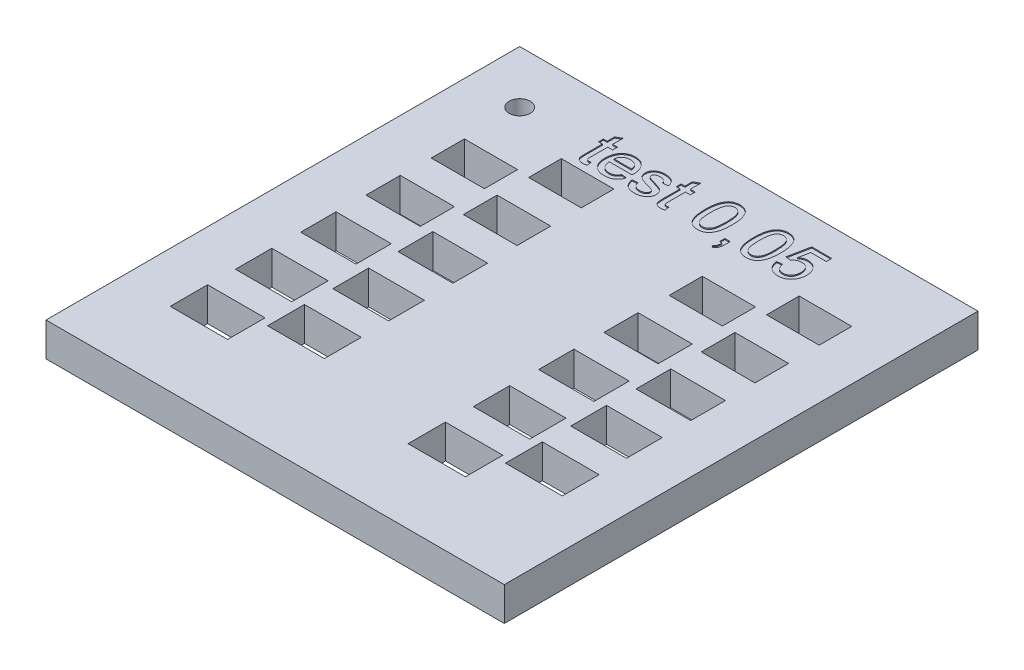
from build123d import *

# Parameters (mm, degrees)
SKETCH_1_W          = 43.5396
SKETCH_1_H          = 45
SKETCH_1_R          = 1
SKETCH_1_W_2        = 5.3
SKETCH_1_H_2        = 3.4
SKETCH_1_W_3        = 5.35
SKETCH_1_H_3        = 3.45
SKETCH_1_W_4        = 5.4
SKETCH_1_H_4        = 3.5
SKETCH_1_W_5        = 5.45
SKETCH_1_H_5        = 3.55
SKETCH_1_W_6        = 5.1
SKETCH_1_H_6        = 3.2
SKETCH_1_W_7        = 5.15
SKETCH_1_H_7        = 3.25
SKETCH_1_W_8        = 5.25
SKETCH_1_H_8        = 3.35
SKETCH_1_W_9        = 5.2
SKETCH_1_H_9        = 3.3
SKETCH_1_W_10       = 5.05
SKETCH_1_H_10       = 3.15
SKETCH_1_W_11       = 5
SKETCH_1_H_11       = 3.1
EXTRUDE_1_DEPTH     = 3.2
CUT_EXTRUDE_1_DEPTH = 0.1


with BuildPart() as part:
    # Эскиз1 → Бобышка-Вытянуть1 (new body)
    with BuildSketch(Plane(origin=(0, 0, 0), x_dir=(1, 0, 0), z_dir=(0, 1, 0))):
        with Locations((21.858709774, 22.465883459)):
            Rectangle(SKETCH_1_W, SKETCH_1_H)
        with Locations((5.088909774, 39.965883459)):
            Circle(SKETCH_1_R, mode=Mode.SUBTRACT)
        with Locations((13.788909774, 17.865583459)):
            Rectangle(SKETCH_1_W_2, SKETCH_1_H_2, mode=Mode.SUBTRACT)
        with Locations((36.388909774, 17.865583459)):
            Rectangle(SKETCH_1_W_2, SKETCH_1_H_2, mode=Mode.SUBTRACT)
        with Locations((30.188909774, 14.865583459)):
            Rectangle(SKETCH_1_W_3, SKETCH_1_H_3, mode=Mode.SUBTRACT)
        with Locations((36.388909774, 11.765583459)):
            Rectangle(SKETCH_1_W_4, SKETCH_1_H_4, mode=Mode.SUBTRACT)
        with Locations((30.188909774, 8.765583459)):
            Rectangle(SKETCH_1_W_5, SKETCH_1_H_5, mode=Mode.SUBTRACT)
        with Locations((7.588909774, 14.865583459)):
            Rectangle(SKETCH_1_W_3, SKETCH_1_H_3, mode=Mode.SUBTRACT)
        with Locations((13.788909774, 30.065583459)):
            Rectangle(SKETCH_1_W_6, SKETCH_1_H_6, mode=Mode.SUBTRACT)
        with Locations((36.388909774, 30.065583459)):
            Rectangle(SKETCH_1_W_6, SKETCH_1_H_6, mode=Mode.SUBTRACT)
        with Locations((7.588909774, 27.065583459)):
            Rectangle(SKETCH_1_W_7, SKETCH_1_H_7, mode=Mode.SUBTRACT)
        with Locations((30.188909774, 27.065583459)):
            Rectangle(SKETCH_1_W_7, SKETCH_1_H_7, mode=Mode.SUBTRACT)
        with Locations((7.588909774, 20.965583459)):
            Rectangle(SKETCH_1_W_8, SKETCH_1_H_8, mode=Mode.SUBTRACT)
        with Locations((30.188909774, 20.965583459)):
            Rectangle(SKETCH_1_W_8, SKETCH_1_H_8, mode=Mode.SUBTRACT)
        with Locations((13.788909774, 23.965583459)):
            Rectangle(SKETCH_1_W_9, SKETCH_1_H_9, mode=Mode.SUBTRACT)
        with Locations((36.388909774, 23.965583459)):
            Rectangle(SKETCH_1_W_9, SKETCH_1_H_9, mode=Mode.SUBTRACT)
        with Locations((7.588909774, 33.165583459)):
            Rectangle(SKETCH_1_W_10, SKETCH_1_H_10, mode=Mode.SUBTRACT)
        with Locations((30.188909774, 33.165583459)):
            Rectangle(SKETCH_1_W_10, SKETCH_1_H_10, mode=Mode.SUBTRACT)
        with Locations((36.388909774, 36.165583459)):
            Rectangle(SKETCH_1_W_11, SKETCH_1_H_11, mode=Mode.SUBTRACT)
        with Locations((13.788909774, 36.165583459)):
            Rectangle(SKETCH_1_W_11, SKETCH_1_H_11, mode=Mode.SUBTRACT)
        with Locations((13.788909774, 11.765583459)):
            Rectangle(SKETCH_1_W_4, SKETCH_1_H_4, mode=Mode.SUBTRACT)
        with Locations((7.588909774, 8.765583459)):
            Rectangle(SKETCH_1_W_5, SKETCH_1_H_5, mode=Mode.SUBTRACT)
    extrude(amount=EXTRUDE_1_DEPTH)

    # Эскиз2 → Вырез-Вытянуть1 (cut)
    with BuildSketch(Plane(origin=(0, 3.2, 0), x_dir=(1, 0, 0), z_dir=(0, 1, 0))):
        with BuildLine():
            Line((13.011600713, 38.82988051), (13.062882764, 38.399592048))
            add(Edge.make_bspline(
                [(13.062882764, 38.399592048), (13.030092724, 38.392817917), (12.966626925, 38.379706446), (12.87347619, 38.366609607), (12.785855685, 38.35660389), (12.729041699, 38.355874879), (12.701504559, 38.355521535)],
                knots=[0, 0, 0, 0, 0.000100416, 0.000194358, 0.000282141, 0.000364708, 0.000364708, 0.000364708, 0.000364708], degree=3))
            add(Edge.make_bspline(
                [(12.701504559, 38.355521535), (12.660597019, 38.356637564), (12.583276952, 38.358746989), (12.474129645, 38.373211148), (12.379453273, 38.399462753), (12.298461322, 38.435567552), (12.231211238, 38.481222634), (12.174630169, 38.53332819), (12.12882532, 38.59198984), (12.098473494, 38.647203628), (12.080606149, 38.698668482), (12.068798566, 38.746659277), (12.059775998, 38.804368147), (12.050764761, 38.870823645), (12.044453563, 38.947040001), (12.041162152, 39.032322522), (12.037316483, 39.127124607), (12.03726744, 39.193390524), (12.037241738, 39.228117689)],
                knots=[0, 0, 0, 0, 0.000122724, 0.000231964, 0.000329371, 0.000416509, 0.000496737, 0.000572147, 0.00064636, 0.000719135, 0.000759938, 0.000809494, 0.000867192, 0.000935075, 0.001010667, 0.001096498, 0.001191104, 0.001295273, 0.001295273, 0.001295273, 0.001295273], degree=3))
            Line((12.037241738, 39.228117689), (12.037241738, 40.868342048))
            Line((12.037241738, 40.868342048), (11.678267379, 40.868342048))
            Line((11.678267379, 40.868342048), (11.678267379, 41.32988051))
            Line((11.678267379, 41.32988051), (12.037241738, 41.32988051))
            Line((12.037241738, 41.32988051), (12.037241738, 42.041418971))
            Line((12.037241738, 42.041418971), (12.550062251, 42.333085638))
            Line((12.550062251, 42.333085638), (12.550062251, 41.32988051))
            Line((12.550062251, 41.32988051), (13.011600713, 41.32988051))
            Line((13.011600713, 41.32988051), (13.011600713, 40.868342048))
            Line((13.011600713, 40.868342048), (12.550062251, 40.868342048))
            Line((12.550062251, 40.868342048), (12.550062251, 39.209688202))
            add(Edge.make_bspline(
                [(12.550062251, 39.209688202), (12.550258863, 39.178427593), (12.550613737, 39.122004189), (12.555506069, 39.046600478), (12.561549378, 38.989339806), (12.574270072, 38.937493723), (12.604007101, 38.890472374), (12.643680727, 38.854791057), (12.683971609, 38.834590474), (12.721328693, 38.82486318), (12.7640469, 38.818381793), (12.794424835, 38.817517014), (12.810478918, 38.817059997)],
                knots=[0, 0, 0, 0, 9.3764e-05, 0.000169237, 0.000226584, 0.000266431, 0.00032827, 0.000390156, 0.000424198, 0.000462501, 0.00050545, 0.000553587, 0.000553587, 0.000553587, 0.000553587], degree=3))
            add(Edge.make_bspline(
                [(12.810478918, 38.817059997), (12.82410351, 38.817237619), (12.853507215, 38.81762095), (12.900793275, 38.820251381), (12.954227146, 38.824200917), (12.991843213, 38.827924652), (13.011600713, 38.82988051)],
                knots=[0, 0, 0, 0, 4.0873e-05, 8.821e-05, 0.000142045, 0.000201605, 0.000201605, 0.000201605, 0.000201605], degree=3))
        make_face()
        with BuildLine():
            Line((15.4675302, 39.278598458), (15.969934046, 39.227316407))
            add(Edge.make_bspline(
                [(15.969934046, 39.227316407), (15.959632776, 39.193427985), (15.939368163, 39.126762829), (15.898251156, 39.032211477), (15.853069118, 38.942383207), (15.79968746, 38.859235476), (15.74111481, 38.78099865), (15.676190637, 38.708296776), (15.603495781, 38.642964233), (15.525732329, 38.582272674), (15.441606387, 38.52893502), (15.352004758, 38.481844229), (15.256599354, 38.442980268), (15.155662463, 38.410604414), (15.048963362, 38.385911501), (14.936700008, 38.368852509), (14.819020517, 38.356766865), (14.738663154, 38.355943384), (14.697498148, 38.355521535)],
                knots=[0, 0, 0, 0, 0.000106172, 0.000208861, 0.000308845, 0.000407543, 0.000504819, 0.00060184, 0.000699399, 0.000797647, 0.000897451, 0.000997803, 0.001100923, 0.001206086, 0.001315513, 0.00142907, 0.001546593, 0.001670032, 0.001670032, 0.001670032, 0.001670032], degree=3))
            add(Edge.make_bspline(
                [(14.697498148, 38.355521535), (14.645889414, 38.356734317), (14.545268386, 38.359098866), (14.398323629, 38.37806788), (14.259522208, 38.408074749), (14.128561841, 38.450589211), (14.006281776, 38.505993341), (13.892371491, 38.574134478), (13.786122453, 38.653438332), (13.68906411, 38.745301507), (13.601249599, 38.847684405), (13.526252418, 38.961525217), (13.461208644, 39.084095671), (13.409476946, 39.217386788), (13.368587894, 39.360064009), (13.340217363, 39.512734533), (13.322065902, 39.674792643), (13.320233299, 39.786293184), (13.31929302, 39.843502305)],
                knots=[0, 0, 0, 0, 0.00015478, 0.000301773, 0.0004437, 0.000580278, 0.000714035, 0.000845545, 0.000977756, 0.001110965, 0.001245678, 0.001381464, 0.001519098, 0.001661198, 0.001809565, 0.00196373, 0.002126547, 0.002298113, 0.002298113, 0.002298113, 0.002298113], degree=3))
            add(Edge.make_bspline(
                [(13.31929302, 39.843502305), (13.320242411, 39.902842451), (13.32208584, 40.018062927), (13.340004575, 40.185823721), (13.369638462, 40.343334753), (13.409850791, 40.491167484), (13.463134787, 40.628607769), (13.528150923, 40.755605503), (13.604497186, 40.872848288), (13.692911054, 40.978619313), (13.790741599, 41.072675556), (13.894880506, 41.156312294), (14.007513363, 41.225334917), (14.126337881, 41.282642256), (14.252499297, 41.326671511), (14.385220442, 41.359096892), (14.525511887, 41.377393645), (14.621324843, 41.379888493), (14.670254559, 41.381162561)],
                knots=[0, 0, 0, 0, 0.000177973, 0.000345569, 0.000505394, 0.000658389, 0.000804513, 0.000946783, 0.001085684, 0.001223365, 0.001359366, 0.001492265, 0.001623237, 0.001754767, 0.001887309, 0.00202335, 0.002163986, 0.00231076, 0.00231076, 0.00231076, 0.00231076], degree=3))
            add(Edge.make_bspline(
                [(14.670254559, 41.381162561), (14.717595918, 41.379945171), (14.810244339, 41.377562702), (14.945977405, 41.358440773), (15.075314606, 41.328559534), (15.197984398, 41.285158668), (15.313369394, 41.2281878), (15.422715757, 41.160191757), (15.525259633, 41.079202613), (15.62034336, 40.986323908), (15.706978788, 40.882598454), (15.781919734, 40.767623983), (15.845376072, 40.643017215), (15.89681693, 40.507825514), (15.936414214, 40.362828103), (15.965101393, 40.207930052), (15.983192886, 40.043184027), (15.985020285, 39.929822413), (15.985959687, 39.871547176)],
                knots=[0, 0, 0, 0, 0.000141972, 0.000277843, 0.000410394, 0.000539646, 0.000667221, 0.000795729, 0.000925252, 0.001058412, 0.001193836, 0.001329849, 0.001469249, 0.001612553, 0.001763017, 0.001919544, 0.00208475, 0.00225952, 0.00225952, 0.00225952, 0.00225952], degree=3))
            add(Edge.make_bspline(
                [(15.985959687, 39.871547176), (15.985715655, 39.853384373), (15.98512707, 39.809577175), (15.984136003, 39.765777129), (15.983555841, 39.74013692)],
                knots=[0, 0, 0, 0, 5.4493e-05, 0.000131433, 0.000131433, 0.000131433, 0.000131433], degree=3))
            Line((15.983555841, 39.74013692), (13.832113533, 39.74013692))
            add(Edge.make_bspline(
                [(13.832113533, 39.74013692), (13.835082372, 39.704021136), (13.840890609, 39.633364226), (13.857828275, 39.531066054), (13.880686064, 39.434926746), (13.911455343, 39.345792819), (13.947804107, 39.262665998), (13.992725061, 39.186913593), (14.042770824, 39.116853131), (14.100272159, 39.054192728), (14.162327253, 38.998456815), (14.228733647, 38.949563862), (14.299373576, 38.909011025), (14.37322512, 38.87491914), (14.450978404, 38.849264953), (14.532278591, 38.830906059), (14.617579422, 38.819420163), (14.675827152, 38.817856739), (14.705510969, 38.817059997)],
                knots=[0, 0, 0, 0, 0.000108673, 0.000212609, 0.000310752, 0.000404762, 0.000495151, 0.000582417, 0.000668486, 0.000753002, 0.00083698, 0.000918396, 0.000999894, 0.001080931, 0.001162015, 0.001245016, 0.00133069, 0.001419722, 0.001419722, 0.001419722, 0.001419722], degree=3))
            add(Edge.make_bspline(
                [(14.705510969, 38.817059997), (14.748851448, 38.818511107), (14.832812907, 38.821322273), (14.953961685, 38.841044629), (15.065013585, 38.8758191), (15.166749028, 38.92409062), (15.258999191, 38.988078436), (15.339495202, 39.069981659), (15.411062122, 39.167051679), (15.448285074, 39.240581727), (15.4675302, 39.278598458)],
                knots=[0, 0, 0, 0, 0.000130008, 0.000251858, 0.000366914, 0.000478015, 0.000588493, 0.000701812, 0.000821049, 0.000948692, 0.000948692, 0.000948692, 0.000948692], degree=3))
        make_face()
        with BuildLine():
            Line((13.832113533, 40.201675381), (15.473139174, 40.201675381))
            add(Edge.make_bspline(
                [(15.473139174, 40.201675381), (15.469911102, 40.227083879), (15.463599514, 40.276763051), (15.450314636, 40.348617764), (15.432596834, 40.415564246), (15.411258457, 40.477351044), (15.385237754, 40.534096442), (15.355838598, 40.585887511), (15.322988733, 40.633277346), (15.297457775, 40.660818349), (15.284837892, 40.674431792)],
                knots=[0, 0, 0, 0, 7.6831e-05, 0.000150222, 0.000219025, 0.000284407, 0.000346079, 0.00040601, 0.000462923, 0.000518553, 0.000518553, 0.000518553, 0.000518553], degree=3))
            add(Edge.make_bspline(
                [(15.284837892, 40.674431792), (15.264674195, 40.694112201), (15.224847448, 40.732984374), (15.158445481, 40.783093091), (15.087082977, 40.824647649), (15.012147308, 40.86050159), (14.931962368, 40.886476832), (14.848133571, 40.90609962), (14.759494002, 40.917215591), (14.698863266, 40.918809048), (14.667850713, 40.919624099)],
                knots=[0, 0, 0, 0, 8.447e-05, 0.000166842, 0.000248746, 0.000331909, 0.000415527, 0.000501051, 0.000589903, 0.000682938, 0.000682938, 0.000682938, 0.000682938], degree=3))
            add(Edge.make_bspline(
                [(14.667850713, 40.919624099), (14.639782113, 40.918972287), (14.584839764, 40.917696409), (14.503897592, 40.908718065), (14.426319679, 40.893834276), (14.352243544, 40.871751008), (14.28139861, 40.844911414), (14.214283008, 40.810602126), (14.150426942, 40.770735927), (14.09008475, 40.725134415), (14.035497286, 40.674029521), (13.98557634, 40.619591439), (13.944246797, 40.559424874), (13.907601917, 40.496333192), (13.878908728, 40.42834739), (13.856320185, 40.35646898), (13.840240668, 40.280499872), (13.834846716, 40.228184328), (13.832113533, 40.201675381)],
                knots=[0, 0, 0, 0, 8.4196e-05, 0.000164807, 0.000244009, 0.000320836, 0.000396428, 0.000470965, 0.000546558, 0.00062204, 0.00069745, 0.000770648, 0.000843118, 0.000915969, 0.000989198, 0.001063958, 0.001141748, 0.001221656, 0.001221656, 0.001221656, 0.001221656], degree=3))
        make_face(mode=Mode.SUBTRACT)
        with BuildLine():
            Line((16.396216097, 39.32988051), (16.90903661, 39.381162561))
            add(Edge.make_bspline(
                [(16.90903661, 39.381162561), (16.916869517, 39.337763789), (16.931870903, 39.254647551), (16.977944653, 39.140101262), (17.040107366, 39.04103343), (17.107064879, 38.972022809), (17.169336129, 38.927561408), (17.219980904, 38.897370919), (17.27565407, 38.872990437), (17.334995153, 38.851898162), (17.398852363, 38.835915514), (17.467197346, 38.824809918), (17.540063873, 38.818582276), (17.590114811, 38.81757583), (17.615767379, 38.817059997)],
                knots=[0, 0, 0, 0, 0.00013202, 0.000252841, 0.000367762, 0.000481086, 0.000538466, 0.000597009, 0.000657621, 0.00072047, 0.000785768, 0.000854795, 0.000927993, 0.001004953, 0.001004953, 0.001004953, 0.001004953], degree=3))
            add(Edge.make_bspline(
                [(17.615767379, 38.817059997), (17.641426671, 38.81719298), (17.691231158, 38.8174511), (17.763146687, 38.824400325), (17.830124196, 38.833638348), (17.891856803, 38.8469925), (17.948215833, 38.864969849), (18.000207993, 38.885342825), (18.046488047, 38.911105155), (18.100141023, 38.948899848), (18.15545979, 39.002427448), (18.205967894, 39.073428989), (18.236995317, 39.151479556), (18.2405722, 39.205682801), (18.242369943, 39.232925381)],
                knots=[0, 0, 0, 0, 7.694e-05, 0.000149339, 0.000216537, 0.000279722, 0.000338517, 0.000393869, 0.000446947, 0.000496968, 0.000590471, 0.000676268, 0.000756924, 0.000838422, 0.000838422, 0.000838422, 0.000838422], degree=3))
            add(Edge.make_bspline(
                [(18.242369943, 39.232925381), (18.242080471, 39.245278983), (18.241512284, 39.269527112), (18.231914041, 39.304271565), (18.218277218, 39.337110611), (18.198599973, 39.367837939), (18.173671104, 39.396574693), (18.143288171, 39.423552642), (18.107391347, 39.448131738), (18.080669097, 39.462100357), (18.066889174, 39.469303587)],
                knots=[0, 0, 0, 0, 3.6937e-05, 7.2502e-05, 0.000107328, 0.000143341, 0.000181408, 0.000221134, 0.00026492, 0.000311539, 0.000311539, 0.000311539, 0.000311539], degree=3))
            add(Edge.make_bspline(
                [(18.066889174, 39.469303587), (18.055458699, 39.474510544), (18.030481665, 39.485888404), (17.988462484, 39.501360282), (17.939705432, 39.519630954), (17.882843371, 39.53630889), (17.819138957, 39.555937294), (17.748041068, 39.577069935), (17.668888165, 39.597129995), (17.613885057, 39.611618556), (17.585318661, 39.61914333)],
                knots=[0, 0, 0, 0, 3.7669e-05, 8.2311e-05, 0.000134271, 0.000193831, 0.000259988, 0.000334283, 0.0004163, 0.000504924, 0.000504924, 0.000504924, 0.000504924], degree=3))
            add(Edge.make_bspline(
                [(17.585318661, 39.61914333), (17.546302494, 39.630559325), (17.471118662, 39.652557852), (17.362941298, 39.685416427), (17.262996636, 39.716785356), (17.171219465, 39.746805139), (17.088034715, 39.776650274), (17.013027791, 39.804450202), (16.946708431, 39.831942724), (16.869785319, 39.864764486), (16.785137931, 39.910945022), (16.695593152, 39.976106533), (16.619814495, 40.052158056), (16.556951058, 40.136650962), (16.507605964, 40.228435201), (16.473448035, 40.326126743), (16.451611105, 40.428280378), (16.448881865, 40.498038827), (16.447498148, 40.533406151)],
                knots=[0, 0, 0, 0, 0.000121956, 0.000235007, 0.000339165, 0.000436213, 0.000524663, 0.000604284, 0.000676155, 0.000740021, 0.00085513, 0.000964589, 0.001071109, 0.001175918, 0.001279519, 0.001382414, 0.001485503, 0.001591517, 0.001591517, 0.001591517, 0.001591517], degree=3))
            add(Edge.make_bspline(
                [(16.447498148, 40.533406151), (16.448607172, 40.56552652), (16.450802224, 40.62910123), (16.467356083, 40.722412756), (16.493717118, 40.81243552), (16.531779908, 40.897956781), (16.578407583, 40.97865651), (16.634738523, 41.051783781), (16.696697829, 41.119480754), (16.744743366, 41.157159045), (16.768812251, 41.176034356)],
                knots=[0, 0, 0, 0, 9.6317e-05, 0.000190637, 0.000283427, 0.000377071, 0.000470797, 0.000562305, 0.00065357, 0.000745186, 0.000745186, 0.000745186, 0.000745186], degree=3))
            add(Edge.make_bspline(
                [(16.768812251, 41.176034356), (16.788872628, 41.19002984), (16.830903236, 41.219353253), (16.901937951, 41.257723784), (16.983457761, 41.291839343), (17.073722431, 41.322404436), (17.170586225, 41.349300337), (17.272313859, 41.367049825), (17.37724423, 41.378829739), (17.44826626, 41.380376535), (17.484357123, 41.381162561)],
                knots=[0, 0, 0, 0, 7.3338e-05, 0.000153658, 0.000241617, 0.000338161, 0.00043943, 0.000542848, 0.000647617, 0.000755865, 0.000755865, 0.000755865, 0.000755865], degree=3))
            add(Edge.make_bspline(
                [(17.484357123, 41.381162561), (17.538094386, 41.379928195), (17.64242805, 41.377531611), (17.793810156, 41.359145118), (17.934927528, 41.327844719), (18.06503133, 41.285177582), (18.182038019, 41.231830235), (18.284522795, 41.169722938), (18.369626205, 41.096818032), (18.439823845, 41.014680868), (18.496108973, 40.920449056), (18.541156361, 40.813190229), (18.577375004, 40.691949292), (18.593117741, 40.605713379), (18.601344302, 40.56064974)],
                knots=[0, 0, 0, 0, 0.000161185, 0.000312949, 0.000456614, 0.000594203, 0.000722921, 0.000841662, 0.000952474, 0.001057637, 0.001164413, 0.001280358, 0.001405842, 0.001543187, 0.001543187, 0.001543187, 0.001543187], degree=3))
            Line((18.601344302, 40.56064974), (18.088523789, 40.509367689))
            add(Edge.make_bspline(
                [(18.088523789, 40.509367689), (18.08242285, 40.540124399), (18.070584761, 40.599803843), (18.034743594, 40.682416416), (17.983849148, 40.753534281), (17.919215189, 40.813901688), (17.840584592, 40.862699467), (17.746597999, 40.895765376), (17.639153572, 40.916966834), (17.562462025, 40.918706602), (17.522017379, 40.919624099)],
                knots=[0, 0, 0, 0, 9.3873e-05, 0.000182149, 0.000267751, 0.000354486, 0.000445878, 0.000543226, 0.000651814, 0.000772977, 0.000772977, 0.000772977, 0.000772977], degree=3))
            add(Edge.make_bspline(
                [(17.522017379, 40.919624099), (17.497704894, 40.919334924), (17.450898369, 40.918778201), (17.383198709, 40.914024719), (17.320961356, 40.905811138), (17.263640644, 40.89617985), (17.212441963, 40.881275559), (17.165880555, 40.864909924), (17.125253594, 40.843954465), (17.079177207, 40.813937521), (17.03333076, 40.770475811), (16.99048553, 40.714035176), (16.964931194, 40.651059357), (16.961855595, 40.607337913), (16.960318661, 40.585489484)],
                knots=[0, 0, 0, 0, 7.2934e-05, 0.000140413, 0.000203425, 0.000261262, 0.000314534, 0.000363208, 0.000409077, 0.000451302, 0.000527845, 0.000597243, 0.000662713, 0.000728109, 0.000728109, 0.000728109, 0.000728109], degree=3))
            add(Edge.make_bspline(
                [(16.960318661, 40.585489484), (16.96083437, 40.571524204), (16.961851366, 40.543984178), (16.972986379, 40.504233199), (16.989891976, 40.46652558), (17.005857237, 40.443960119), (17.014004559, 40.432444612)],
                knots=[0, 0, 0, 0, 4.179e-05, 8.2411e-05, 0.000122929, 0.000165155, 0.000165155, 0.000165155, 0.000165155], degree=3))
            add(Edge.make_bspline(
                [(17.014004559, 40.432444612), (17.023772922, 40.420836227), (17.044099838, 40.396680423), (17.083908318, 40.366627716), (17.13022993, 40.338386572), (17.16496263, 40.323316295), (17.183075071, 40.315457433)],
                knots=[0, 0, 0, 0, 4.5384e-05, 9.4439e-05, 0.00014872, 0.000207874, 0.000207874, 0.000207874, 0.000207874], degree=3))
            add(Edge.make_bspline(
                [(17.183075071, 40.315457433), (17.190005043, 40.313009852), (17.206175738, 40.307298561), (17.234870845, 40.298559284), (17.271124613, 40.287374323), (17.315819415, 40.274585423), (17.368096802, 40.259373443), (17.428809763, 40.242569364), (17.497114983, 40.223350768), (17.545511033, 40.210184092), (17.570895584, 40.203277946)],
                knots=[0, 0, 0, 0, 2.2046e-05, 5.1444e-05, 8.9972e-05, 0.000135869, 0.000190902, 0.000253309, 0.000324852, 0.000403774, 0.000403774, 0.000403774, 0.000403774], degree=3))
            add(Edge.make_bspline(
                [(17.570895584, 40.203277946), (17.608577699, 40.191863721), (17.681348646, 40.169820798), (17.786748876, 40.13663506), (17.884877387, 40.105711349), (17.975450973, 40.076129937), (18.058408724, 40.047756763), (18.134149869, 40.021741638), (18.202452622, 39.99666479), (18.282568577, 39.966644041), (18.373588214, 39.926191641), (18.470159736, 39.864853137), (18.554810082, 39.79363351), (18.62664133, 39.712474762), (18.685006135, 39.620698722), (18.725432483, 39.517599566), (18.751295755, 39.404598741), (18.753863434, 39.325756016), (18.755190456, 39.285008715)],
                knots=[0, 0, 0, 0, 0.000118118, 0.000228107, 0.0003315, 0.000426775, 0.000513942, 0.000594526, 0.000667023, 0.000732203, 0.000851239, 0.000965055, 0.001074217, 0.001182084, 0.001289019, 0.00139868, 0.001512795, 0.001634853, 0.001634853, 0.001634853, 0.001634853], degree=3))
            add(Edge.make_bspline(
                [(18.755190456, 39.285008715), (18.753528226, 39.24399393), (18.750212263, 39.162174066), (18.72234328, 39.041913303), (18.678872245, 38.924884717), (18.617166568, 38.813517853), (18.539520021, 38.709413531), (18.444706701, 38.617485041), (18.334111467, 38.538206837), (18.209235865, 38.472717232), (18.072934297, 38.419149086), (17.926178879, 38.383680203), (17.771257556, 38.358807289), (17.664751136, 38.356635), (17.610158405, 38.355521535)],
                knots=[0, 0, 0, 0, 0.000122913, 0.000245197, 0.000368428, 0.000496455, 0.000625782, 0.000756676, 0.000890995, 0.001032586, 0.00117871, 0.001329129, 0.00148472, 0.001648341, 0.001648341, 0.001648341, 0.001648341], degree=3))
            add(Edge.make_bspline(
                [(17.610158405, 38.355521535), (17.56526337, 38.356312766), (17.478265023, 38.357846026), (17.351862552, 38.369015377), (17.233677707, 38.38798369), (17.123794091, 38.415117976), (17.022151297, 38.449628593), (16.928460309, 38.491165513), (16.842925091, 38.541049365), (16.765591875, 38.598988337), (16.695956916, 38.665022248), (16.632591648, 38.737797534), (16.576210479, 38.818391038), (16.527528911, 38.906604128), (16.483880648, 39.001504065), (16.447220937, 39.104179348), (16.417499431, 39.214370396), (16.403422601, 39.290768963), (16.396216097, 39.32988051)],
                knots=[0, 0, 0, 0, 0.000134675, 0.000260975, 0.000380323, 0.000493429, 0.000600108, 0.000701969, 0.000800367, 0.00089652, 0.000991184, 0.001087744, 0.001185553, 0.001285639, 0.001389621, 0.001498607, 0.001612316, 0.001731589, 0.001731589, 0.001731589, 0.001731589], degree=3))
        make_face()
        with BuildLine():
            Line((20.396216097, 38.82988051), (20.447498148, 38.399592048))
            add(Edge.make_bspline(
                [(20.447498148, 38.399592048), (20.414708109, 38.392817917), (20.351242309, 38.379706446), (20.258091574, 38.366609607), (20.17047107, 38.35660389), (20.113657083, 38.355874879), (20.086119943, 38.355521535)],
                knots=[0, 0, 0, 0, 0.000100416, 0.000194358, 0.000282141, 0.000364708, 0.000364708, 0.000364708, 0.000364708], degree=3))
            add(Edge.make_bspline(
                [(20.086119943, 38.355521535), (20.045212404, 38.356637564), (19.967892337, 38.358746989), (19.85874503, 38.373211148), (19.764068657, 38.399462753), (19.683076707, 38.435567552), (19.615826623, 38.481222634), (19.559245554, 38.53332819), (19.513440705, 38.59198984), (19.483088879, 38.647203628), (19.465221534, 38.698668482), (19.45341395, 38.746659277), (19.444391382, 38.804368147), (19.435380146, 38.870823645), (19.429068948, 38.947040001), (19.425777536, 39.032322522), (19.421931867, 39.127124607), (19.421882824, 39.193390524), (19.421857123, 39.228117689)],
                knots=[0, 0, 0, 0, 0.000122724, 0.000231964, 0.000329371, 0.000416509, 0.000496737, 0.000572147, 0.00064636, 0.000719135, 0.000759938, 0.000809494, 0.000867192, 0.000935075, 0.001010667, 0.001096498, 0.001191104, 0.001295273, 0.001295273, 0.001295273, 0.001295273], degree=3))
            Line((19.421857123, 39.228117689), (19.421857123, 40.868342048))
            Line((19.421857123, 40.868342048), (19.062882764, 40.868342048))
            Line((19.062882764, 40.868342048), (19.062882764, 41.32988051))
            Line((19.062882764, 41.32988051), (19.421857123, 41.32988051))
            Line((19.421857123, 41.32988051), (19.421857123, 42.041418971))
            Line((19.421857123, 42.041418971), (19.934677636, 42.333085638))
            Line((19.934677636, 42.333085638), (19.934677636, 41.32988051))
            Line((19.934677636, 41.32988051), (20.396216097, 41.32988051))
            Line((20.396216097, 41.32988051), (20.396216097, 40.868342048))
            Line((20.396216097, 40.868342048), (19.934677636, 40.868342048))
            Line((19.934677636, 40.868342048), (19.934677636, 39.209688202))
            add(Edge.make_bspline(
                [(19.934677636, 39.209688202), (19.934874248, 39.178427593), (19.935229121, 39.122004189), (19.940121454, 39.046600478), (19.946164762, 38.989339806), (19.958885457, 38.937493723), (19.988622486, 38.890472374), (20.028296111, 38.854791057), (20.068586993, 38.834590474), (20.105944078, 38.82486318), (20.148662285, 38.818381793), (20.17904022, 38.817517014), (20.195094302, 38.817059997)],
                knots=[0, 0, 0, 0, 9.3764e-05, 0.000169237, 0.000226584, 0.000266431, 0.00032827, 0.000390156, 0.000424198, 0.000462501, 0.00050545, 0.000553587, 0.000553587, 0.000553587, 0.000553587], degree=3))
            add(Edge.make_bspline(
                [(20.195094302, 38.817059997), (20.208718895, 38.817237619), (20.2381226, 38.81762095), (20.285408659, 38.820251381), (20.33884253, 38.824200917), (20.376458598, 38.827924652), (20.396216097, 38.82988051)],
                knots=[0, 0, 0, 0, 4.0873e-05, 8.821e-05, 0.000142045, 0.000201605, 0.000201605, 0.000201605, 0.000201605], degree=3))
        make_face()
        with BuildLine():
            add(Edge.make_bspline(
                [(22.293651995, 40.379559997), (22.294168661, 40.436723669), (22.295180594, 40.548683229), (22.301457283, 40.712500179), (22.312415875, 40.868070353), (22.328774034, 41.015258646), (22.34814516, 41.154397291), (22.373327746, 41.285287723), (22.401661816, 41.408223615), (22.435657616, 41.523076826), (22.473007871, 41.630834886), (22.515382926, 41.731324925), (22.563060612, 41.824440402), (22.613697866, 41.911146975), (22.669960337, 41.990096), (22.728452135, 42.063503111), (22.793424096, 42.128676182), (22.862174545, 42.187292122), (22.93571585, 42.239017273), (23.013658906, 42.28364984), (23.095703808, 42.323057178), (23.183414242, 42.352723012), (23.274969355, 42.376906955), (23.371073892, 42.394696957), (23.471833759, 42.405184764), (23.540688964, 42.406257883), (23.575703277, 42.406803587)],
                knots=[0, 0, 0, 0, 0.000171491, 0.000335879, 0.000491732, 0.00063924, 0.000780095, 0.000913045, 0.001038989, 0.001158412, 0.001272197, 0.001380988, 0.001485269, 0.001585861, 0.001681898, 0.001775881, 0.001867104, 0.001957492, 0.002046637, 0.002136384, 0.002226712, 0.002319207, 0.002413663, 0.002510632, 0.002612129, 0.002717146, 0.002717146, 0.002717146, 0.002717146], degree=3))
            add(Edge.make_bspline(
                [(23.575703277, 42.406803587), (23.627073827, 42.405293329), (23.727993335, 42.402326367), (23.875336337, 42.378128362), (24.014197621, 42.336733946), (24.144486967, 42.280891093), (24.263977102, 42.209959921), (24.370686828, 42.123732276), (24.46346511, 42.023113529), (24.541299415, 41.906911383), (24.609334367, 41.778331468), (24.669775125, 41.636796669), (24.724411815, 41.482465594), (24.763183199, 41.344317736), (24.790838796, 41.225063604), (24.809144604, 41.126706169), (24.824342094, 41.020577943), (24.835985425, 40.906935679), (24.845538504, 40.785906836), (24.852915909, 40.65741606), (24.856660697, 40.52114221), (24.857383103, 40.427638805), (24.857754559, 40.379559997)],
                knots=[0, 0, 0, 0, 0.000154055, 0.000302647, 0.000446398, 0.000587806, 0.000726874, 0.000861901, 0.000998001, 0.001135796, 0.001280262, 0.001433875, 0.001597085, 0.001771098, 0.001864008, 0.001964274, 0.002071134, 0.002185549, 0.002306924, 0.002435332, 0.002571608, 0.002715848, 0.002715848, 0.002715848, 0.002715848], degree=3))
            add(Edge.make_bspline(
                [(24.857754559, 40.379559997), (24.857228214, 40.322664831), (24.856199896, 40.211508926), (24.850091393, 40.049005512), (24.83847247, 39.894609039), (24.824175173, 39.74796583), (24.802546357, 39.609467352), (24.779240136, 39.478525164), (24.750416097, 39.355733856), (24.716785212, 39.241039614), (24.678909197, 39.133835975), (24.637372287, 39.033312753), (24.59136617, 38.939538638), (24.539521532, 38.853428256), (24.484210498, 38.773838634), (24.425027975, 38.700471215), (24.360719224, 38.634381968), (24.291349226, 38.575941844), (24.218324273, 38.523299422), (24.140191724, 38.478226197), (24.057293552, 38.440883813), (23.970183632, 38.40895793), (23.877978109, 38.385564516), (23.781404106, 38.367657222), (23.680105794, 38.357112111), (23.610984263, 38.356059042), (23.575703277, 38.355521535)],
                knots=[0, 0, 0, 0, 0.00017069, 0.000333477, 0.000487731, 0.000635154, 0.000775333, 0.000908135, 0.001034079, 0.001153503, 0.001266532, 0.001375013, 0.00147965, 0.001579554, 0.001676247, 0.001770229, 0.001862024, 0.001952413, 0.002042021, 0.002131768, 0.002222486, 0.002314494, 0.002409725, 0.002507482, 0.002608979, 0.002714797, 0.002714797, 0.002714797, 0.002714797], degree=3))
            add(Edge.make_bspline(
                [(23.575703277, 38.355521535), (23.529445812, 38.356841032), (23.439256489, 38.359413687), (23.307541632, 38.376893295), (23.183920213, 38.407658225), (23.067349557, 38.448918334), (22.959139949, 38.504106106), (22.858774731, 38.571252808), (22.764237137, 38.648796199), (22.70981555, 38.709976155), (22.682273789, 38.740938202)],
                knots=[0, 0, 0, 0, 0.00013877, 0.000270563, 0.000397662, 0.000520339, 0.000640745, 0.000760975, 0.000882138, 0.001006285, 0.001006285, 0.001006285, 0.001006285], degree=3))
            add(Edge.make_bspline(
                [(22.682273789, 38.740938202), (22.650572589, 38.786667648), (22.585203358, 38.880963724), (22.50869434, 39.04174728), (22.440446941, 39.218747401), (22.386885246, 39.415436808), (22.344933087, 39.630250075), (22.314633154, 39.863608713), (22.297486375, 40.115411902), (22.294958974, 40.289522969), (22.293651995, 40.379559997)],
                knots=[0, 0, 0, 0, 0.000166682, 0.000343706, 0.0005324, 0.000735364, 0.000954266, 0.001188624, 0.001440844, 0.001710952, 0.001710952, 0.001710952, 0.001710952], degree=3))
        make_face()
        with BuildLine():
            add(Edge.make_bspline(
                [(22.806472507, 40.381162561), (22.806981697, 40.304228012), (22.8079564, 40.156958268), (22.818139672, 39.946558031), (22.835669757, 39.756748297), (22.858845674, 39.587791871), (22.889447269, 39.439460205), (22.92787119, 39.312131294), (22.971184088, 39.204276903), (23.024782978, 39.117233803), (23.083467843, 39.04628098), (23.144055956, 38.985259257), (23.207972744, 38.93339219), (23.27480116, 38.890145633), (23.345578094, 38.857402182), (23.419529612, 38.833669656), (23.496671805, 38.820011951), (23.549209143, 38.818049596), (23.575703277, 38.817059997)],
                knots=[0, 0, 0, 0, 0.000230791, 0.000441786, 0.000631708, 0.000802479, 0.000953191, 0.001085506, 0.001201138, 0.001300772, 0.001390751, 0.001476873, 0.00155834, 0.001637249, 0.00171504, 0.001791569, 0.001869689, 0.001949162, 0.001949162, 0.001949162, 0.001949162], degree=3))
            add(Edge.make_bspline(
                [(23.575703277, 38.817059997), (23.602190775, 38.818071219), (23.654714958, 38.820076452), (23.732035395, 38.833432991), (23.805699185, 38.858387251), (23.87637059, 38.891015053), (23.943684735, 38.93327589), (24.007287609, 38.985338871), (24.068194888, 39.046324361), (24.126616142, 39.118101882), (24.179806683, 39.205547411), (24.223932078, 39.313313944), (24.261757184, 39.440865845), (24.292526695, 39.589121937), (24.315798216, 39.75781123), (24.333222312, 39.947094518), (24.343473734, 40.157224039), (24.34443235, 40.304227665), (24.344934046, 40.381162561)],
                knots=[0, 0, 0, 0, 7.9472e-05, 0.000157592, 0.000234369, 0.00031216, 0.00039064, 0.000472107, 0.000558229, 0.000648831, 0.000749148, 0.000864042, 0.000997125, 0.001147836, 0.001317814, 0.001507736, 0.00171793, 0.001948722, 0.001948722, 0.001948722, 0.001948722], degree=3))
            add(Edge.make_bspline(
                [(24.344934046, 40.381162561), (24.344448414, 40.456496691), (24.343517961, 40.600834033), (24.333002141, 40.807180904), (24.316522906, 40.993804759), (24.293981931, 41.160877647), (24.264024979, 41.308218188), (24.227691283, 41.43614005), (24.184394251, 41.544370418), (24.132914234, 41.633996469), (24.075606676, 41.707514145), (24.015743498, 41.771150091), (23.951828116, 41.82527039), (23.88272814, 41.868686492), (23.810670795, 41.903712988), (23.734000384, 41.927819114), (23.653470517, 41.942629165), (23.598203914, 41.944376432), (23.570094302, 41.945265125)],
                knots=[0, 0, 0, 0, 0.000225984, 0.000432977, 0.000619635, 0.000787914, 0.000938461, 0.00107032, 0.001186384, 0.001287263, 0.001379257, 0.001465409, 0.001549023, 0.001629714, 0.001709637, 0.001788701, 0.001870117, 0.001954389, 0.001954389, 0.001954389, 0.001954389], degree=3))
            add(Edge.make_bspline(
                [(23.570094302, 41.945265125), (23.543601833, 41.944569802), (23.491362079, 41.943198715), (23.414876237, 41.9301117), (23.342391503, 41.908227294), (23.273077436, 41.878582742), (23.208664426, 41.838687029), (23.146598012, 41.792105946), (23.089785144, 41.735352094), (23.055550209, 41.692923801), (23.03804302, 41.671226664)],
                knots=[0, 0, 0, 0, 7.9428e-05, 0.000156622, 0.000231913, 0.000306194, 0.00038205, 0.000458655, 0.000538547, 0.000622161, 0.000622161, 0.000622161, 0.000622161], degree=3))
            add(Edge.make_bspline(
                [(23.03804302, 41.671226664), (23.018983033, 41.639360288), (22.978732353, 41.572065213), (22.933694182, 41.455103599), (22.893909242, 41.321438738), (22.861153046, 41.169014098), (22.837456237, 40.998091149), (22.818748522, 40.808868386), (22.80903056, 40.601081631), (22.807348717, 40.456491463), (22.806472507, 40.381162561)],
                knots=[0, 0, 0, 0, 0.000111217, 0.000234866, 0.000374549, 0.000529514, 0.000701985, 0.000891984, 0.001099777, 0.001325774, 0.001325774, 0.001325774, 0.001325774], degree=3))
        make_face(mode=Mode.SUBTRACT)
        with BuildLine():
            Line((25.626985328, 38.406803587), (25.626985328, 38.919624099))
            Line((25.626985328, 38.919624099), (26.139805841, 38.919624099))
            Line((26.139805841, 38.919624099), (26.139805841, 38.406803587))
            add(Edge.make_bspline(
                [(26.139805841, 38.406803587), (26.13864046, 38.355993355), (26.13641773, 38.259082971), (26.118088926, 38.121542492), (26.088259145, 37.998784981), (26.044821063, 37.890643822), (25.988078244, 37.795394541), (25.915792326, 37.713188479), (25.829529602, 37.641765646), (25.763333417, 37.605036109), (25.72954943, 37.586290766)],
                knots=[0, 0, 0, 0, 0.000152378, 0.000290632, 0.000415398, 0.000530417, 0.000638978, 0.000746317, 0.000857326, 0.000973033, 0.000973033, 0.000973033, 0.000973033], degree=3))
            Line((25.72954943, 37.586290766), (25.626985328, 37.791418971))
            add(Edge.make_bspline(
                [(25.626985328, 37.791418971), (25.647243838, 37.804105646), (25.687557917, 37.829351905), (25.739339008, 37.879226895), (25.782007459, 37.937829129), (25.817383535, 38.00547995), (25.844716601, 38.0850971), (25.863853258, 38.179078351), (25.877468275, 38.287846827), (25.880295942, 38.365624852), (25.88179302, 38.406803587)],
                knots=[0, 0, 0, 0, 7.1561e-05, 0.000142406, 0.000214043, 0.000288234, 0.000370595, 0.000465678, 0.0005755, 0.000699064, 0.000699064, 0.000699064, 0.000699064], degree=3))
            Line((25.88179302, 38.406803587), (25.626985328, 38.406803587))
        make_face()
        with BuildLine():
            add(Edge.make_bspline(
                [(26.90903661, 40.379559997), (26.909553277, 40.436723669), (26.910565209, 40.548683229), (26.916841899, 40.712500179), (26.92780049, 40.868070353), (26.94415865, 41.015258646), (26.963529776, 41.154397291), (26.988712362, 41.285287723), (27.017046432, 41.408223615), (27.051042231, 41.523076826), (27.088392486, 41.630834886), (27.130767541, 41.731324925), (27.178445227, 41.824440402), (27.229082481, 41.911146975), (27.285344952, 41.990096), (27.343836751, 42.063503111), (27.408808711, 42.128676182), (27.47755916, 42.187292122), (27.551100466, 42.239017273), (27.629043521, 42.28364984), (27.711088424, 42.323057178), (27.798798857, 42.352723012), (27.890353971, 42.376906955), (27.986458508, 42.394696957), (28.087218374, 42.405184764), (28.156073579, 42.406257883), (28.191087892, 42.406803587)],
                knots=[0, 0, 0, 0, 0.000171491, 0.000335879, 0.000491732, 0.00063924, 0.000780095, 0.000913045, 0.001038989, 0.001158412, 0.001272197, 0.001380988, 0.001485269, 0.001585861, 0.001681898, 0.001775881, 0.001867104, 0.001957492, 0.002046637, 0.002136384, 0.002226712, 0.002319207, 0.002413663, 0.002510632, 0.002612129, 0.002717146, 0.002717146, 0.002717146, 0.002717146], degree=3))
            add(Edge.make_bspline(
                [(28.191087892, 42.406803587), (28.242458443, 42.405293329), (28.34337795, 42.402326367), (28.490720953, 42.378128362), (28.629582236, 42.336733946), (28.759871583, 42.280891093), (28.879361717, 42.209959921), (28.986071444, 42.123732276), (29.078849725, 42.023113529), (29.156684031, 41.906911383), (29.224718983, 41.778331468), (29.285159741, 41.636796669), (29.33979643, 41.482465594), (29.378567815, 41.344317736), (29.406223411, 41.225063604), (29.424529219, 41.126706169), (29.439726709, 41.020577943), (29.451370041, 40.906935679), (29.460923119, 40.785906836), (29.468300524, 40.65741606), (29.472045313, 40.52114221), (29.472767718, 40.427638805), (29.473139174, 40.379559997)],
                knots=[0, 0, 0, 0, 0.000154055, 0.000302647, 0.000446398, 0.000587806, 0.000726874, 0.000861901, 0.000998001, 0.001135796, 0.001280262, 0.001433875, 0.001597085, 0.001771098, 0.001864008, 0.001964274, 0.002071134, 0.002185549, 0.002306924, 0.002435332, 0.002571608, 0.002715848, 0.002715848, 0.002715848, 0.002715848], degree=3))
            add(Edge.make_bspline(
                [(29.473139174, 40.379559997), (29.472612829, 40.322664831), (29.471584511, 40.211508926), (29.465476008, 40.049005512), (29.453857085, 39.894609039), (29.439559788, 39.74796583), (29.417930972, 39.609467352), (29.394624751, 39.478525164), (29.365800713, 39.355733856), (29.332169827, 39.241039614), (29.294293813, 39.133835975), (29.252756902, 39.033312753), (29.206750786, 38.939538638), (29.154906147, 38.853428256), (29.099595114, 38.773838634), (29.040412591, 38.700471215), (28.976103839, 38.634381968), (28.906733842, 38.575941844), (28.833708889, 38.523299422), (28.755576339, 38.478226197), (28.672678167, 38.440883813), (28.585568248, 38.40895793), (28.493362724, 38.385564516), (28.396788722, 38.367657222), (28.29549041, 38.357112111), (28.226368879, 38.356059042), (28.191087892, 38.355521535)],
                knots=[0, 0, 0, 0, 0.00017069, 0.000333477, 0.000487731, 0.000635154, 0.000775333, 0.000908135, 0.001034079, 0.001153503, 0.001266532, 0.001375013, 0.00147965, 0.001579554, 0.001676247, 0.001770229, 0.001862024, 0.001952413, 0.002042021, 0.002131768, 0.002222486, 0.002314494, 0.002409725, 0.002507482, 0.002608979, 0.002714797, 0.002714797, 0.002714797, 0.002714797], degree=3))
            add(Edge.make_bspline(
                [(28.191087892, 38.355521535), (28.144830428, 38.356841032), (28.054641104, 38.359413687), (27.922926247, 38.376893295), (27.799304829, 38.407658225), (27.682734172, 38.448918334), (27.574524564, 38.504106106), (27.474159346, 38.571252808), (27.379621752, 38.648796199), (27.325200166, 38.709976155), (27.297658405, 38.740938202)],
                knots=[0, 0, 0, 0, 0.00013877, 0.000270563, 0.000397662, 0.000520339, 0.000640745, 0.000760975, 0.000882138, 0.001006285, 0.001006285, 0.001006285, 0.001006285], degree=3))
            add(Edge.make_bspline(
                [(27.297658405, 38.740938202), (27.265957205, 38.786667648), (27.200587973, 38.880963724), (27.124078955, 39.04174728), (27.055831557, 39.218747401), (27.002269862, 39.415436808), (26.960317703, 39.630250075), (26.93001777, 39.863608713), (26.912870991, 40.115411902), (26.91034359, 40.289522969), (26.90903661, 40.379559997)],
                knots=[0, 0, 0, 0, 0.000166682, 0.000343706, 0.0005324, 0.000735364, 0.000954266, 0.001188624, 0.001440844, 0.001710952, 0.001710952, 0.001710952, 0.001710952], degree=3))
        make_face()
        with BuildLine():
            add(Edge.make_bspline(
                [(27.421857123, 40.381162561), (27.422366313, 40.304228012), (27.423341015, 40.156958268), (27.433524288, 39.946558031), (27.451054373, 39.756748297), (27.47423029, 39.587791871), (27.504831884, 39.439460205), (27.543255805, 39.312131294), (27.586568703, 39.204276903), (27.640167593, 39.117233803), (27.698852458, 39.04628098), (27.759440571, 38.985259257), (27.82335736, 38.93339219), (27.890185776, 38.890145633), (27.960962709, 38.857402182), (28.034914227, 38.833669656), (28.11205642, 38.820011951), (28.164593759, 38.818049596), (28.191087892, 38.817059997)],
                knots=[0, 0, 0, 0, 0.000230791, 0.000441786, 0.000631708, 0.000802479, 0.000953191, 0.001085506, 0.001201138, 0.001300772, 0.001390751, 0.001476873, 0.00155834, 0.001637249, 0.00171504, 0.001791569, 0.001869689, 0.001949162, 0.001949162, 0.001949162, 0.001949162], degree=3))
            add(Edge.make_bspline(
                [(28.191087892, 38.817059997), (28.217575391, 38.818071219), (28.270099574, 38.820076452), (28.347420011, 38.833432991), (28.4210838, 38.858387251), (28.491755205, 38.891015053), (28.55906935, 38.93327589), (28.622672225, 38.985338871), (28.683579503, 39.046324361), (28.742000757, 39.118101882), (28.795191299, 39.205547411), (28.839316694, 39.313313944), (28.877141799, 39.440865845), (28.90791131, 39.589121937), (28.931182832, 39.75781123), (28.948606928, 39.947094518), (28.958858349, 40.157224039), (28.959816966, 40.304227665), (28.960318661, 40.381162561)],
                knots=[0, 0, 0, 0, 7.9472e-05, 0.000157592, 0.000234369, 0.00031216, 0.00039064, 0.000472107, 0.000558229, 0.000648831, 0.000749148, 0.000864042, 0.000997125, 0.001147836, 0.001317814, 0.001507736, 0.00171793, 0.001948722, 0.001948722, 0.001948722, 0.001948722], degree=3))
            add(Edge.make_bspline(
                [(28.960318661, 40.381162561), (28.959833029, 40.456496691), (28.958902577, 40.600834033), (28.948386757, 40.807180904), (28.931907522, 40.993804759), (28.909366546, 41.160877647), (28.879409594, 41.308218188), (28.843075898, 41.43614005), (28.799778866, 41.544370418), (28.74829885, 41.633996469), (28.690991291, 41.707514145), (28.631128113, 41.771150091), (28.567212731, 41.82527039), (28.498112756, 41.868686492), (28.42605541, 41.903712988), (28.349384999, 41.927819114), (28.268855132, 41.942629165), (28.213588529, 41.944376432), (28.185478918, 41.945265125)],
                knots=[0, 0, 0, 0, 0.000225984, 0.000432977, 0.000619635, 0.000787914, 0.000938461, 0.00107032, 0.001186384, 0.001287263, 0.001379257, 0.001465409, 0.001549023, 0.001629714, 0.001709637, 0.001788701, 0.001870117, 0.001954389, 0.001954389, 0.001954389, 0.001954389], degree=3))
            add(Edge.make_bspline(
                [(28.185478918, 41.945265125), (28.158986448, 41.944569802), (28.106746694, 41.943198715), (28.030260852, 41.9301117), (27.957776118, 41.908227294), (27.888462052, 41.878582742), (27.824049041, 41.838687029), (27.761982627, 41.792105946), (27.70516976, 41.735352094), (27.670934824, 41.692923801), (27.653427636, 41.671226664)],
                knots=[0, 0, 0, 0, 7.9428e-05, 0.000156622, 0.000231913, 0.000306194, 0.00038205, 0.000458655, 0.000538547, 0.000622161, 0.000622161, 0.000622161, 0.000622161], degree=3))
            add(Edge.make_bspline(
                [(27.653427636, 41.671226664), (27.634367648, 41.639360288), (27.594116968, 41.572065213), (27.549078797, 41.455103599), (27.509293858, 41.321438738), (27.476537662, 41.169014098), (27.452840852, 40.998091149), (27.434133137, 40.808868386), (27.424415176, 40.601081631), (27.422733333, 40.456491463), (27.421857123, 40.381162561)],
                knots=[0, 0, 0, 0, 0.000111217, 0.000234866, 0.000374549, 0.000529514, 0.000701985, 0.000891984, 0.001099777, 0.001325774, 0.001325774, 0.001325774, 0.001325774], degree=3))
        make_face(mode=Mode.SUBTRACT)
        with BuildLine():
            Line((29.985959687, 39.483726664), (30.4987802, 39.535008715))
            add(Edge.make_bspline(
                [(30.4987802, 39.535008715), (30.503857928, 39.506114093), (30.513734899, 39.449909561), (30.532556559, 39.368551833), (30.557000537, 39.29296823), (30.584466038, 39.222504154), (30.61711342, 39.157904675), (30.652487128, 39.098149801), (30.694203187, 39.045360643), (30.738062023, 38.99677628), (30.786200446, 38.953964863), (30.839082957, 38.917873362), (30.895234098, 38.886385713), (30.95533777, 38.860605025), (31.019486089, 38.841734918), (31.086862617, 38.826811904), (31.158334949, 38.819292267), (31.207100034, 38.817813602), (31.231953277, 38.817059997)],
                knots=[0, 0, 0, 0, 8.801e-05, 0.000171193, 0.000250256, 0.000326141, 0.00039781, 0.000467208, 0.000534042, 0.000599261, 0.000663409, 0.000726756, 0.000790964, 0.000856301, 0.000922459, 0.000991295, 0.001063058, 0.001137646, 0.001137646, 0.001137646, 0.001137646], degree=3))
            add(Edge.make_bspline(
                [(31.231953277, 38.817059997), (31.262442638, 38.817796708), (31.322065911, 38.81923738), (31.40880648, 38.831421999), (31.490739973, 38.851513026), (31.567474349, 38.879628924), (31.639909172, 38.914594371), (31.705641459, 38.959868255), (31.768255297, 39.010760575), (31.823721473, 39.071433987), (31.874211276, 39.13748713), (31.917787772, 39.209586947), (31.954473025, 39.286721457), (31.985357998, 39.368875874), (32.008164297, 39.456519517), (32.024940172, 39.549186139), (32.035709614, 39.646934768), (32.036723788, 39.713932988), (32.037241738, 39.74814974)],
                knots=[0, 0, 0, 0, 9.1434e-05, 0.000178803, 0.000262175, 0.000344051, 0.000423604, 0.00050272, 0.000582949, 0.000665153, 0.000748648, 0.000832062, 0.00091736, 0.001004579, 0.001094957, 0.001188628, 0.001286938, 0.001389552, 0.001389552, 0.001389552, 0.001389552], degree=3))
            add(Edge.make_bspline(
                [(32.037241738, 39.74814974), (32.036653044, 39.78075786), (32.035506721, 39.84425343), (32.025852811, 39.936713539), (32.009565527, 40.023654021), (31.988491306, 40.106033114), (31.959443151, 40.182563543), (31.924990404, 40.254354924), (31.882784341, 40.319883632), (31.83582731, 40.381189995), (31.782196453, 40.436148679), (31.721167225, 40.482554326), (31.655133767, 40.523168639), (31.582766098, 40.556104314), (31.504021604, 40.580574282), (31.419682788, 40.599401721), (31.32887451, 40.609304183), (31.266428922, 40.611040187), (31.234357123, 40.611931792)],
                knots=[0, 0, 0, 0, 9.7809e-05, 0.000190457, 0.000278466, 0.000363012, 0.000445166, 0.000523647, 0.00060145, 0.000678544, 0.000755036, 0.000831005, 0.000907962, 0.000987208, 0.001068805, 0.001154934, 0.001246076, 0.001342314, 0.001342314, 0.001342314, 0.001342314], degree=3))
            add(Edge.make_bspline(
                [(31.234357123, 40.611931792), (31.194477397, 40.610765232), (31.117997109, 40.608528034), (31.008102799, 40.58970729), (30.908062029, 40.559304775), (30.819007459, 40.513993526), (30.739441601, 40.459861797), (30.667711518, 40.398609289), (30.603225722, 40.330277415), (30.567852637, 40.278831446), (30.550062251, 40.252957433)],
                knots=[0, 0, 0, 0, 0.000119563, 0.000229295, 0.000333452, 0.000431997, 0.000527783, 0.00062156, 0.000714543, 0.000808625, 0.000808625, 0.000808625, 0.000808625], degree=3))
            Line((30.550062251, 40.252957433), (30.037241738, 40.304239484))
            Line((30.037241738, 40.304239484), (30.447498148, 42.355521535))
            Line((30.447498148, 42.355521535), (32.344934046, 42.355521535))
            Line((32.344934046, 42.355521535), (32.344934046, 41.842701023))
            Line((32.344934046, 41.842701023), (30.866568661, 41.842701023))
            Line((30.866568661, 41.842701023), (30.66304302, 40.80664333))
            add(Edge.make_bspline(
                [(30.66304302, 40.80664333), (30.691339083, 40.827877092), (30.746908074, 40.869576842), (30.833585739, 40.924177167), (30.921502804, 40.970201601), (31.010147481, 41.007891742), (31.100223913, 41.037252295), (31.191188536, 41.057650652), (31.283351071, 41.071437062), (31.345151487, 41.07279059), (31.376184046, 41.073470253)],
                knots=[0, 0, 0, 0, 0.0001061, 0.000208363, 0.000306924, 0.000403511, 0.000497014, 0.000590705, 0.000682947, 0.000775982, 0.000775982, 0.000775982, 0.000775982], degree=3))
            add(Edge.make_bspline(
                [(31.376184046, 41.073470253), (31.416570818, 41.072412088), (31.496102166, 41.070328303), (31.613294361, 41.053207391), (31.725349814, 41.024143506), (31.833147478, 40.984998691), (31.935265914, 40.933105552), (32.03273951, 40.87027398), (32.12517473, 40.79598607), (32.212049011, 40.711643484), (32.29084744, 40.618014347), (32.361374605, 40.518152244), (32.418977342, 40.410058212), (32.467425196, 40.296554604), (32.503965605, 40.175778217), (32.531701052, 40.049443115), (32.546530274, 39.91596982), (32.548866499, 39.825105577), (32.550062251, 39.778598458)],
                knots=[0, 0, 0, 0, 0.000121124, 0.000238522, 0.000354351, 0.000467924, 0.000581878, 0.000697232, 0.000815238, 0.000937067, 0.001059875, 0.001181907, 0.001303091, 0.001426614, 0.001551565, 0.001681066, 0.001814151, 0.001953687, 0.001953687, 0.001953687, 0.001953687], degree=3))
            add(Edge.make_bspline(
                [(32.550062251, 39.778598458), (32.549154253, 39.734223022), (32.547360698, 39.646568872), (32.532662142, 39.517394279), (32.508449765, 39.392924391), (32.476036072, 39.272790614), (32.432240824, 39.157675217), (32.379121288, 39.047206365), (32.317844923, 38.940231355), (32.268704458, 38.874287436), (32.243972507, 38.841098458)],
                knots=[0, 0, 0, 0, 0.0001331, 0.00026291, 0.000389413, 0.000513242, 0.000635723, 0.000758295, 0.000880745, 0.001004817, 0.001004817, 0.001004817, 0.001004817], degree=3))
            add(Edge.make_bspline(
                [(32.243972507, 38.841098458), (32.212551258, 38.802356477), (32.150742286, 38.72614684), (32.043720726, 38.627231293), (31.928671031, 38.543166691), (31.804908528, 38.474870294), (31.673264073, 38.419988356), (31.532120451, 38.383466487), (31.383183139, 38.358940605), (31.280934785, 38.356676907), (31.228748148, 38.355521535)],
                knots=[0, 0, 0, 0, 0.000149488, 0.000294059, 0.000435741, 0.000575986, 0.000717198, 0.000862392, 0.001012439, 0.001168855, 0.001168855, 0.001168855, 0.001168855], degree=3))
            add(Edge.make_bspline(
                [(31.228748148, 38.355521535), (31.185702453, 38.35639471), (31.101496431, 38.358102816), (30.978203834, 38.372952275), (30.860937994, 38.396631927), (30.749662175, 38.430595878), (30.644041132, 38.473512508), (30.545302572, 38.528031345), (30.451732994, 38.590397498), (30.365390616, 38.662532458), (30.286721468, 38.742990671), (30.216232314, 38.8300674), (30.154877064, 38.923819425), (30.102685331, 39.023685756), (30.059185932, 39.129570618), (30.025907171, 39.242196715), (29.999547624, 39.360459012), (29.99053649, 39.442206616), (29.985959687, 39.483726664)],
                knots=[0, 0, 0, 0, 0.000129096, 0.000252538, 0.000371969, 0.000487554, 0.00060109, 0.000713321, 0.000825329, 0.000937977, 0.001050167, 0.001162418, 0.00127354, 0.001385722, 0.0015, 0.001616351, 0.001737681, 0.00186291, 0.00186291, 0.00186291, 0.00186291], degree=3))
        make_face()
    extrude(amount=-CUT_EXTRUDE_1_DEPTH, mode=Mode.SUBTRACT)


solid = part.part
